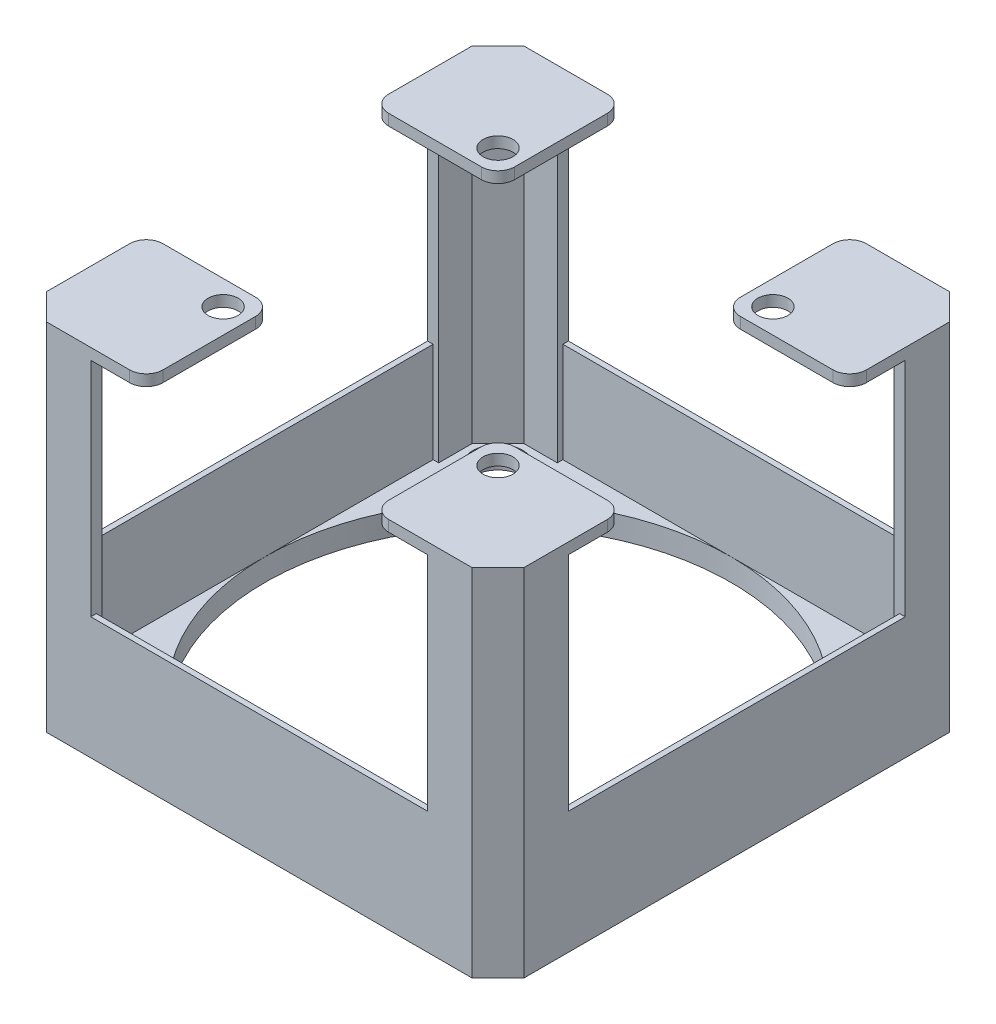
from build123d import *

# Parameters (mm, degrees)
SKETCH1_R           = 21
BOSS_EXTRUDE1_DEPTH = 2
BOSS_EXTRUDE6_DEPTH = 30
SKETCH13_W          = 30.324405
SKETCH13_H          = 0.5
SKETCH13_W_2        = 0.5
SKETCH13_H_2        = 30.324404
SKETCH13_W_3        = 30.32440476
SKETCH13_H_3        = 0.50000019
BOSS_EXTRUDE7_DEPTH = 9
SKETCH15_R          = 1.35
BOSS_EXTRUDE9_DEPTH = 1
SKETCH16_R          = 2.25
CUT_EXTRUDE1_DEPTH  = 3


with BuildPart() as part:
    # Sketch1 → Boss-Extrude1 (new body)
    with BuildSketch(Plane(origin=(0, 0, 0), x_dir=(1, 0, 0), z_dir=(0, 1, 0))):
        Polygon((0, 0), (38.32440476, 0), (40.66220238, 2.33779762), (40.66220238, 40.66220238), (38.32440476, 43), (0, 43), (-2.33779762, 40.66220238), (-2.33779762, 2.33779762), align=None)
        with Locations((19.16220238, 21.5)):
            Circle(SKETCH1_R, mode=Mode.SUBTRACT)
    extrude(amount=BOSS_EXTRUDE1_DEPTH)

    # Sketch3 → Boss-Extrude6 (add)
    with BuildSketch(Plane(origin=(0, 2, 0), x_dir=(1, 0, 0), z_dir=(0, 1, 0))):
        Polygon((34.324405, 1), (34.324405, 0), (38.32440476, 0), (40.66220238, 2.33779762), (40.66220238, 6.337798), (39.66220238, 6.337798), (39.66220238, 3.33779738), (37.324405, 1), align=None)
        Polygon((-2.33779762, 2.33779762), (0, 0), (4, 0), (4, 1), (1, 1), (-1.33779762, 3.337798), (-1.33779762, 6.337798), (-2.33779762, 6.337798), align=None)
        Polygon((-2.33779762, 40.66220238), (-2.33779762, 36.662202), (-1.33779762, 36.662202), (-1.33779762, 39.662202), (1, 41.99999962), (4, 41.99999962), (4, 43), (0, 43), align=None)
        Polygon((39.66220238, 39.662202), (37.32440476, 41.99999962), (34.32440476, 41.99999962), (34.32440476, 43), (38.32440476, 43), (40.66220238, 40.66220238), (40.66220238, 36.662202), (39.66220238, 36.662202), align=None)
    extrude(amount=BOSS_EXTRUDE6_DEPTH)

    # Sketch13 → Boss-Extrude7 (add)
    with BuildSketch(Plane(origin=(0, 2, 0), x_dir=(1, 0, 0), z_dir=(0, 1, 0))):
        with Locations((19.1622025, 0.25)):
            Rectangle(SKETCH13_W, SKETCH13_H)
        with Locations((-2.08779762, 21.5)):
            Rectangle(SKETCH13_W_2, SKETCH13_H_2)
        with Locations((40.41220238, 21.5)):
            Rectangle(SKETCH13_W_2, SKETCH13_H_2)
        with Locations((19.16220238, 42.749999905)):
            Rectangle(SKETCH13_W_3, SKETCH13_H_3)
    extrude(amount=BOSS_EXTRUDE7_DEPTH)

    # Sketch15 → Boss-Extrude9 (add)
    with BuildSketch(Plane(origin=(0, 32, 0), x_dir=(1, 0, 0), z_dir=(0, 1, 0))):
        with BuildLine():
            Line((4, 0), (7.5, 0))
            ThreePointArc((7.5, 0), (8.560660172, 0.439339828), (9, 1.5))
            Line((9, 1.5), (9, 9.837798))
            ThreePointArc((9, 9.837798), (8.560660172, 10.898458172), (7.5, 11.337798))
            Line((7.5, 11.337798), (-0.83779762, 11.337798))
            ThreePointArc((-0.83779762, 11.337798), (-1.898457792, 10.898458172), (-2.33779762, 9.837798))
            Line((-2.33779762, 9.837798), (-2.33779762, 6.337798))
            Line((-2.33779762, 6.337798), (-2.33779762, 2.33779762))
            Line((-2.33779762, 2.33779762), (0, 0))
            Line((0, 0), (4, 0))
        make_face()
        with Locations((6.78783338, 9.125631)):
            Circle(SKETCH15_R, mode=Mode.SUBTRACT)
        with BuildLine():
            Line((39.16220238, 11.337798), (30.82440476, 11.337798))
            ThreePointArc((30.82440476, 11.337798), (29.763744588, 10.898458172), (29.32440476, 9.837798))
            Line((29.32440476, 9.837798), (29.32440476, 1.5))
            ThreePointArc((29.32440476, 1.5), (29.763744588, 0.439339828), (30.82440476, 0))
            Line((30.82440476, 0), (34.32440476, 0))
            Line((34.32440476, 0), (38.32440476, 0))
            Line((38.32440476, 0), (40.66220238, 2.33779762))
            Line((40.66220238, 2.33779762), (40.66220238, 6.337798))
            Line((40.66220238, 6.337798), (40.66220238, 9.837798))
            ThreePointArc((40.66220238, 9.837798), (40.222862552, 10.898458172), (39.16220238, 11.337798))
        make_face()
        with Locations((31.53657138, 9.125631)):
            Circle(SKETCH15_R, mode=Mode.SUBTRACT)
        with BuildLine():
            Line((-0.83779762, 31.662202), (7.5, 31.662202))
            ThreePointArc((7.5, 31.662202), (8.560660172, 32.101541828), (9, 33.162202))
            Line((9, 33.162202), (9, 41.5))
            ThreePointArc((9, 41.5), (8.560660172, 42.560660171), (7.5, 43))
            Line((7.5, 43), (4, 43))
            Line((4, 43), (0, 43))
            Line((0, 43), (-2.33779762, 40.66220238))
            Line((-2.33779762, 40.66220238), (-2.33779762, 36.662202))
            Line((-2.33779762, 36.662202), (-2.33779762, 33.162202))
            ThreePointArc((-2.33779762, 33.162202), (-1.898457792, 32.101541828), (-0.83779762, 31.662202))
        make_face()
        with Locations((6.78783338, 33.874369)):
            Circle(SKETCH15_R, mode=Mode.SUBTRACT)
        with BuildLine():
            Line((40.66220238, 36.662202), (40.66220238, 33.162202))
            ThreePointArc((40.66220238, 33.162202), (40.222862552, 32.101541828), (39.16220238, 31.662202))
            Line((39.16220238, 31.662202), (30.82440476, 31.662202))
            ThreePointArc((30.82440476, 31.662202), (29.763744588, 32.101541828), (29.32440476, 33.162202))
            Line((29.32440476, 33.162202), (29.32440476, 41.5))
            ThreePointArc((29.32440476, 41.5), (29.763744588, 42.560660171), (30.82440476, 43))
            Line((30.82440476, 43), (34.32440476, 43))
            Line((34.32440476, 43), (38.32440476, 43))
            Line((38.32440476, 43), (40.66220238, 40.66220238))
            Line((40.66220238, 40.66220238), (40.66220238, 36.662202))
        make_face()
        with Locations((31.53657138, 33.874369)):
            Circle(SKETCH15_R, mode=Mode.SUBTRACT)
    extrude(amount=-BOSS_EXTRUDE9_DEPTH)

    # Sketch16 → Cut-Extrude1 (cut, through all)
    with BuildSketch(Plane(origin=(0, 2, 0), x_dir=(1, 0, 0), z_dir=(0, 1, 0))):
        with Locations((36.83987191, 39.177669529)):
            Circle(SKETCH16_R)
        with Locations((36.83987191, 3.82233047)):
            Circle(SKETCH16_R)
        with Locations((1.48453285, 3.82233047)):
            Circle(SKETCH16_R)
        with Locations((1.48453285, 39.177669529)):
            Circle(SKETCH16_R)
    extrude(amount=-CUT_EXTRUDE1_DEPTH, mode=Mode.SUBTRACT)


solid = part.part
